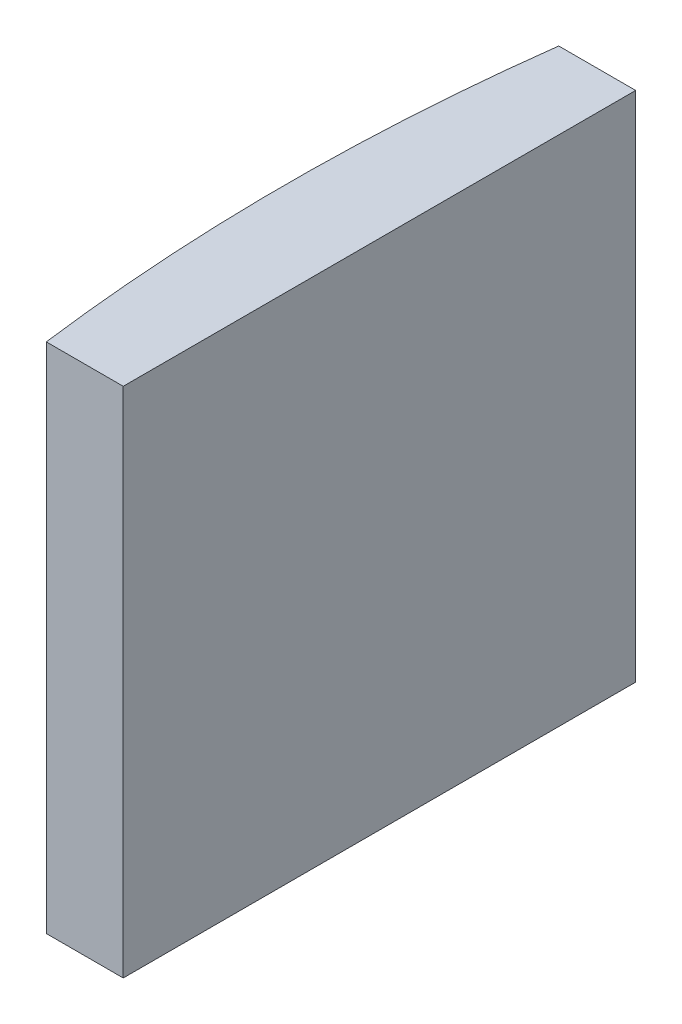
from build123d import *

# Parameters (mm, degrees)
EXTRUDE_1_DEPTH = 20


with BuildPart() as part:
    # 草图1 → 凸台-拉伸1 (new body)
    with BuildSketch(Plane(origin=(0, 0, 0), x_dir=(1, 0, 0), z_dir=(0, 1, 0))):
        with BuildLine():
            Line((-72.547347638, 10), (-69.544795665, 10))
            Line((-69.544795665, 10), (-69.544795665, -10))
            Line((-69.544795665, -10), (-72.547347638, -10))
            ThreePointArc((-72.547347638, -10), (-73.194795665, 0), (-72.547347638, 10))
        make_face()
    extrude(amount=EXTRUDE_1_DEPTH)


solid = part.part
